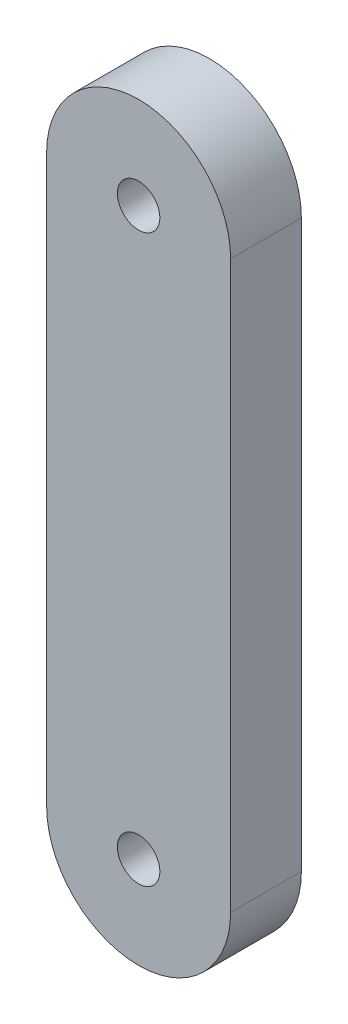
from build123d import *

# Parameters (mm, degrees)
SKETCH1_R           = 0.75
BOSS_EXTRUDE1_DEPTH = 2.5


with BuildPart() as part:
    # Sketch1 → Boss-Extrude1 (new body)
    with BuildSketch(Plane.XY):
        with BuildLine():
            Line((-3.25, 0), (-3.25, 20))
            ThreePointArc((-3.25, 20), (0, 23.25), (3.25, 20))
            Line((3.25, 20), (3.25, 0))
            ThreePointArc((3.25, 0), (0, -3.25), (-3.25, 0))
        make_face()
        with Locations((0, 20)):
            Circle(SKETCH1_R, mode=Mode.SUBTRACT)
        Circle(SKETCH1_R, mode=Mode.SUBTRACT)
    extrude(amount=BOSS_EXTRUDE1_DEPTH)


solid = part.part
